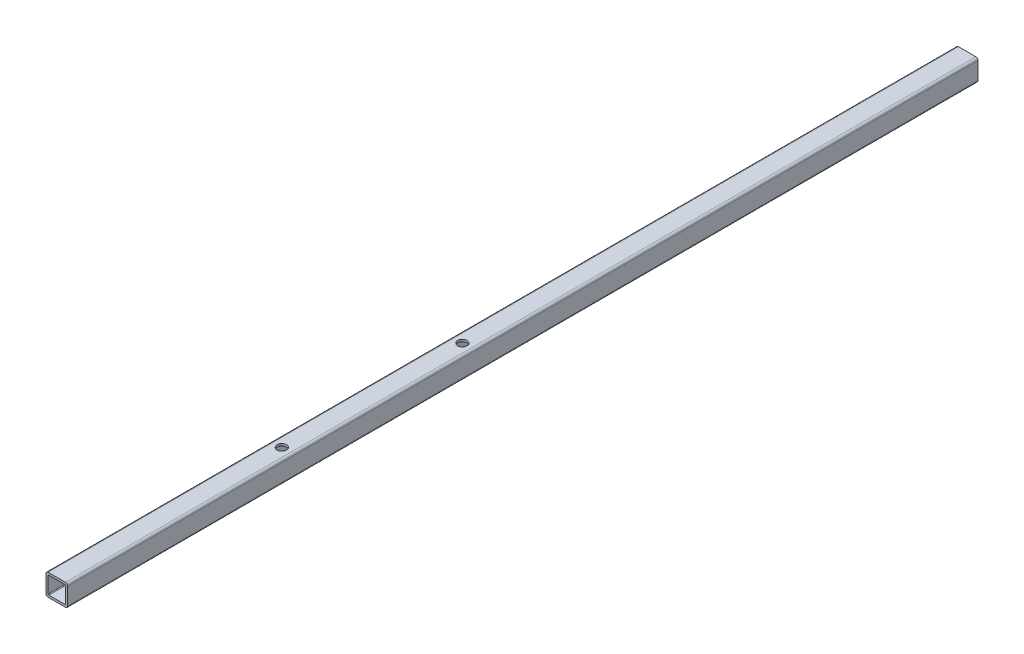
from build123d import *

# Parameters (mm, degrees)
DODANIE_WYCI_GNI_CIE1_DEPTH = 1260
SZKIC6_R                    = 6.5
WYTNIJ_WYCI_GNI_CIE5_DEPTH  = 30


with BuildPart() as part:
    # Szkic1 → Dodanie-wyci_gni_cie1 (new body)
    with BuildSketch(Plane.XY):
        with BuildLine():
            Line((-12, -15), (12, -15))
            ThreePointArc((12, -15), (14.121320344, -14.121320344), (15, -12))
            Line((15, -12), (15, 12))
            ThreePointArc((15, 12), (14.121320344, 14.121320344), (12, 15))
            Line((12, 15), (-12, 15))
            ThreePointArc((-12, 15), (-14.121320344, 14.121320344), (-15, 12))
            Line((-15, 12), (-15, -12))
            ThreePointArc((-15, -12), (-14.121320344, -14.121320344), (-12, -15))
        make_face()
        with BuildLine():
            Line((-11, -12), (11, -12))
            ThreePointArc((11, -12), (11.707106781, -11.707106781), (12, -11))
            Line((12, -11), (12, 11))
            ThreePointArc((12, 11), (11.707106781, 11.707106781), (11, 12))
            Line((11, 12), (-11, 12))
            ThreePointArc((-11, 12), (-11.707106781, 11.707106781), (-12, 11))
            Line((-12, 11), (-12, -11))
            ThreePointArc((-12, -11), (-11.707106781, -11.707106781), (-11, -12))
        make_face(mode=Mode.SUBTRACT)
    extrude(amount=DODANIE_WYCI_GNI_CIE1_DEPTH)

    # Szkic6 → Wytnij-wyci_gni_cie5 (cut)
    with BuildSketch(Plane(origin=(0, 15, 0), x_dir=(1, 0, 0), z_dir=(0, 1, 0))):
        with Locations((0, -948.6)):
            Circle(SZKIC6_R)
        with Locations((0, -698.6)):
            Circle(SZKIC6_R)
    extrude(amount=-WYTNIJ_WYCI_GNI_CIE5_DEPTH, mode=Mode.SUBTRACT)


solid = part.part
